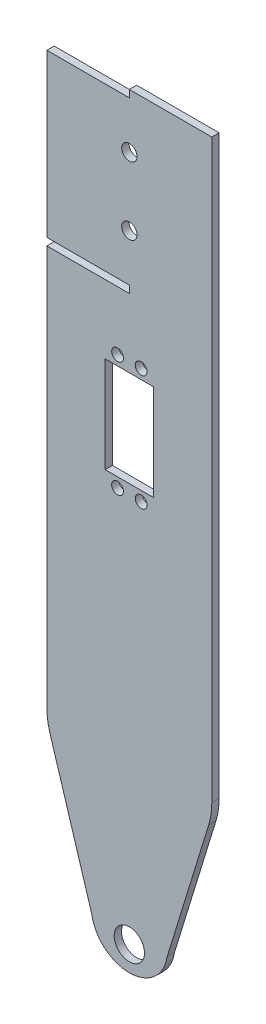
from build123d import *

# Parameters (mm, degrees)
SKETCH1_W               = 70
SKETCH1_H               = 349.15
SKETCH1_R               = 6.425
SKETCH1_R_2             = 2.5
SKETCH1_W_2             = 20.5
SKETCH1_H_2             = 40.7
BOSS_EXTRUDE1_DEPTH     = 3.1
CUT_EXTRUDE1_DEPTH      = 1
CUT_EXTRUDE1_DEPTH_BACK = 4.1
FILLET2_R               = 30
SKETCH4_R               = 3.25
SKETCH4_W               = 35
SKETCH4_H               = 3.1
CUT_EXTRUDE2_DEPTH      = 4.1


with BuildPart() as part:
    # Sketch1 → Boss-Extrude1 (new body)
    with BuildSketch(Plane.XY):
        Rectangle(SKETCH1_W, SKETCH1_H)
        with Locations((0, -139.575)):
            Circle(SKETCH1_R, mode=Mode.SUBTRACT)
        with Locations((-5, 74.575)):
            Circle(SKETCH1_R_2, mode=Mode.SUBTRACT)
        with Locations((5, 74.575)):
            Circle(SKETCH1_R_2, mode=Mode.SUBTRACT)
        with Locations((5, 25.575)):
            Circle(SKETCH1_R_2, mode=Mode.SUBTRACT)
        with Locations((-5, 25.575)):
            Circle(SKETCH1_R_2, mode=Mode.SUBTRACT)
        with Locations((0, 50.075)):
            Rectangle(SKETCH1_W_2, SKETCH1_H_2, mode=Mode.SUBTRACT)
    extrude(amount=BOSS_EXTRUDE1_DEPTH)

    # Sketch2 → Cut-Extrude1 (cut, two sides)
    with BuildSketch(Plane.XY.offset(3.1)) as cut_extrude1_sk:
        with BuildLine():
            Line((-16, -136.269781362), (-35, -74.575))
            Line((-35, -74.575), (-35, -174.575))
            Line((-35, -174.575), (35, -174.575))
            Line((35, -174.575), (35, -74.575))
            Line((35, -74.575), (16, -136.269781362))
            ThreePointArc((16, -136.269781362), (0, -150.051383336), (-16, -136.269781362))
        make_face()
    extrude(amount=CUT_EXTRUDE1_DEPTH, mode=Mode.SUBTRACT)
    extrude(cut_extrude1_sk.sketch, amount=-CUT_EXTRUDE1_DEPTH_BACK, mode=Mode.SUBTRACT)

    # Fillet2
    fillet2_edges = [part.edges().sort_by_distance(p)[0] for p in [
        (-35, -74.575, 1.55),
        (35, -74.575, 1.55),
    ]]
    fillet(fillet2_edges, radius=FILLET2_R)

    # Sketch4 → Cut-Extrude2 (cut, through all)
    with BuildSketch(Plane.XY.offset(3.1)):
        with Locations((0, 122.675)):
            Circle(SKETCH4_R)
        with Locations((0, 151.475)):
            Circle(SKETCH4_R)
        with Locations((-17.5, 173.025)):
            Rectangle(SKETCH4_W, SKETCH4_H)
        with Locations((-17.5, 101.125)):
            Rectangle(SKETCH4_W, SKETCH4_H)
    extrude(amount=-CUT_EXTRUDE2_DEPTH, mode=Mode.SUBTRACT)


solid = part.part
